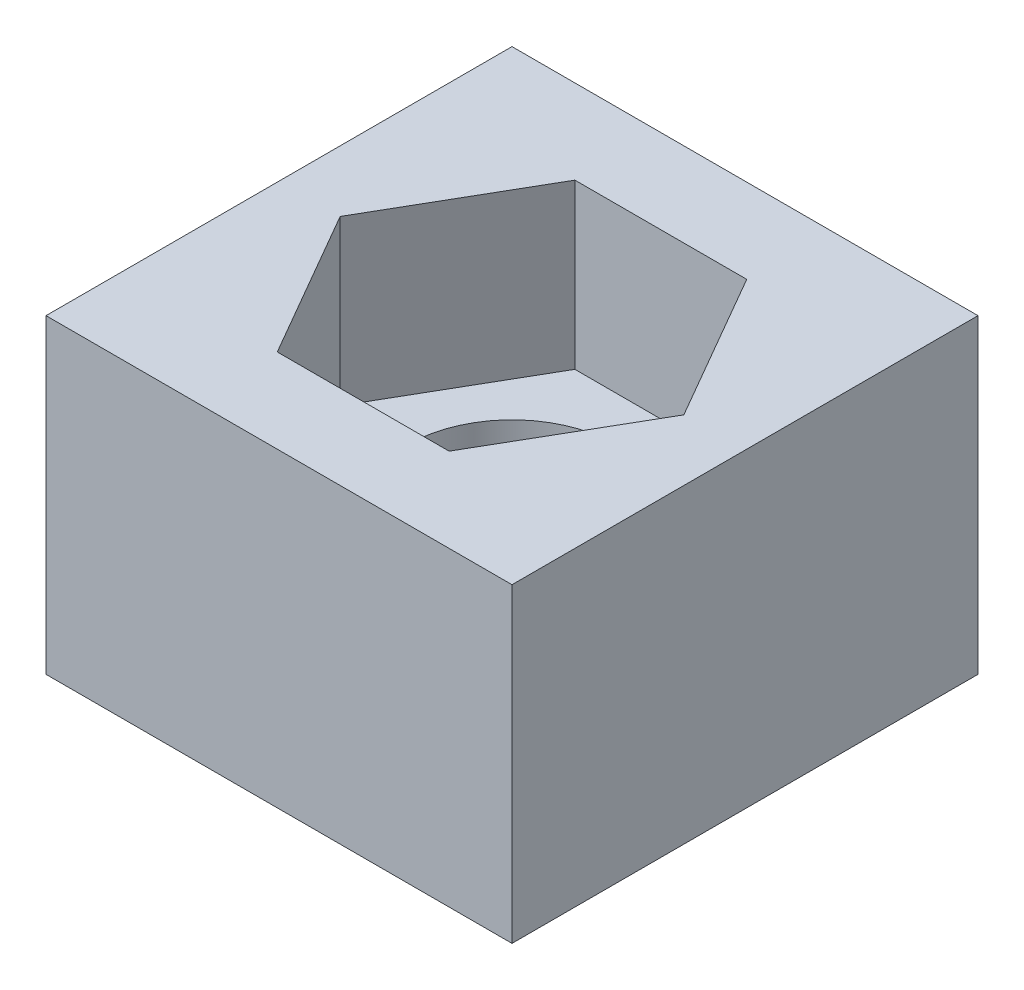
from build123d import *

# Parameters (mm, degrees)
SKETCH1_W           = 38.101827682
SKETCH1_H           = 38.101827682
BOSS_EXTRUDE1_DEPTH = 25.4
CUT_EXTRUDE1_DEPTH  = 13.4
SKETCH4_R           = 8.523044684
CUT_EXTRUDE2_DEPTH  = 12


with BuildPart() as part:
    # Sketch1 → Boss-Extrude1 (new body)
    with BuildSketch(Plane(origin=(0, 0, 0), x_dir=(1, 0, 0), z_dir=(0, 1, 0))):
        with Locations((19.050913841, 19.050913841)):
            Rectangle(SKETCH1_W, SKETCH1_H)
    extrude(amount=BOSS_EXTRUDE1_DEPTH)

    # Sketch2 → Cut-Extrude1 (cut)
    with BuildSketch(Plane(origin=(0, 25.4, 0), x_dir=(1, 0, 0), z_dir=(0, 1, 0))):
        Polygon((33.100912857, 19.050913841), (26.075913349, 31.218569912), (12.025914333, 31.218569912), (5.000914826, 19.050913841), (12.025914333, 6.883257771), (26.075913349, 6.883257771), align=None)
    extrude(amount=-CUT_EXTRUDE1_DEPTH, mode=Mode.SUBTRACT)

    # Sketch4 → Cut-Extrude2 (cut)
    with BuildSketch(Plane.XZ):
        with Locations((19.050913841, -19.050913841)):
            Circle(SKETCH4_R)
    extrude(amount=-CUT_EXTRUDE2_DEPTH, mode=Mode.SUBTRACT)


solid = part.part
